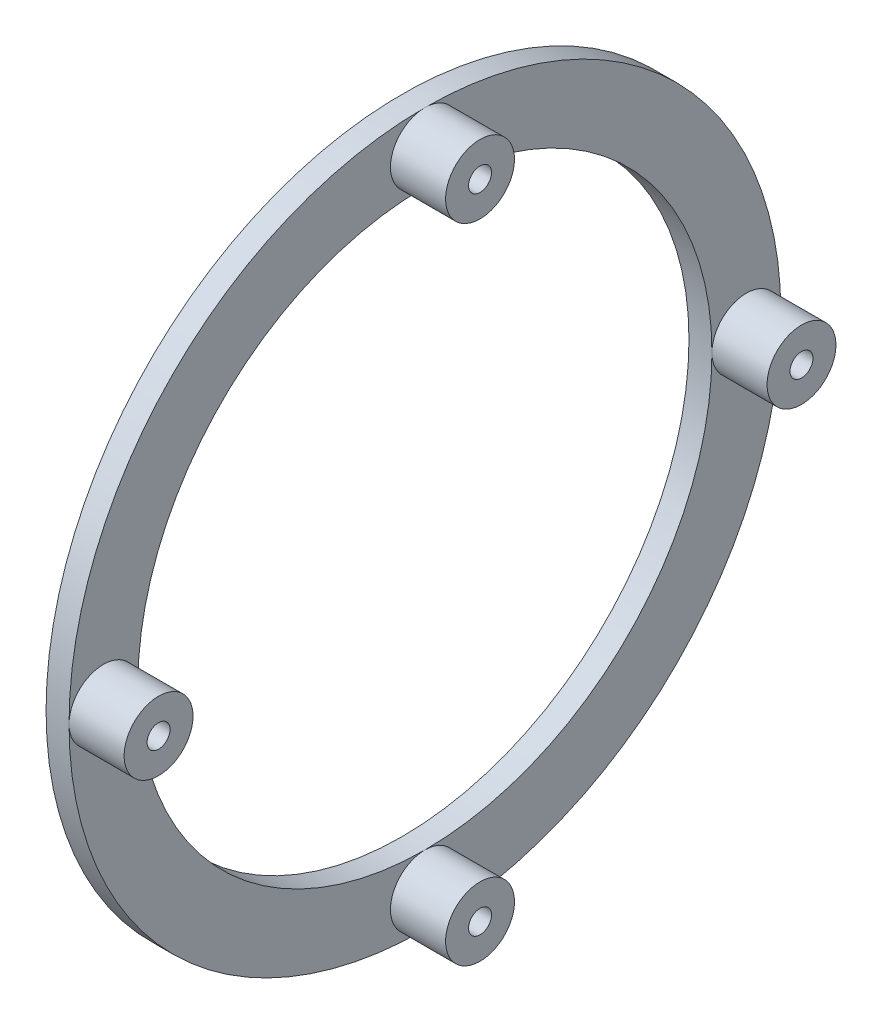
from build123d import *

# Parameters (mm, degrees)
SKETCH1_R           = 98.425
SKETCH1_R_2         = 79.375
BOSS_EXTRUDE1_DEPTH = 6.35
BOSS_EXTRUDE2_START = 6.35
SKETCH2_R           = 9.525
BOSS_EXTRUDE2_DEPTH = 15.24
CIRPATTERN2_COUNT   = 4


with BuildPart() as part:
    # Sketch1 → Boss-Extrude1 (new body)
    with BuildSketch(Plane(origin=(0, 0, 0), x_dir=(0, 0, -1), z_dir=(1, 0, 0))):
        Circle(SKETCH1_R)
        Circle(SKETCH1_R_2, mode=Mode.SUBTRACT)
    extrude(amount=BOSS_EXTRUDE1_DEPTH)

    # Sketch2 → Boss-Extrude2 (add)
    with BuildSketch(Plane(origin=(0, 0, 0), x_dir=(0, 0, -1), z_dir=(1, 0, 0)).offset(BOSS_EXTRUDE2_START)):
        with Locations((88.9, 0)):
            Circle(SKETCH2_R)
    boss_extrude2 = extrude(amount=BOSS_EXTRUDE2_DEPTH)

    # Sketch4 → 1/4 (0.2500) Dowel Hole1 (revolve, cut)
    with BuildSketch(Plane(origin=(21.59, 0, -88.9), x_dir=(0, 0, -1), z_dir=(0, 1, 0))):
        Polygon((0, 0), (0, 14.607732465), (3.175, 12.7), (3.175, 0), align=None)
    f_1_4_0_2500_dowel_hole1 = revolve(axis=Axis((27.94, 0, -88.9), (-1, 0, 0)), mode=Mode.SUBTRACT)

    # CirPattern2: Boss-Extrude2, 1/4 (0.2500) Dowel Hole1 ×4 about axis
    cirpattern2_axis = Axis((0, 0, 0), (1, 0, 0))
    for i in range(1, CIRPATTERN2_COUNT):
        add(boss_extrude2.rotate(cirpattern2_axis, i * 360 / CIRPATTERN2_COUNT))
        add(f_1_4_0_2500_dowel_hole1.rotate(cirpattern2_axis, i * 360 / CIRPATTERN2_COUNT), mode=Mode.SUBTRACT)


solid = part.part
